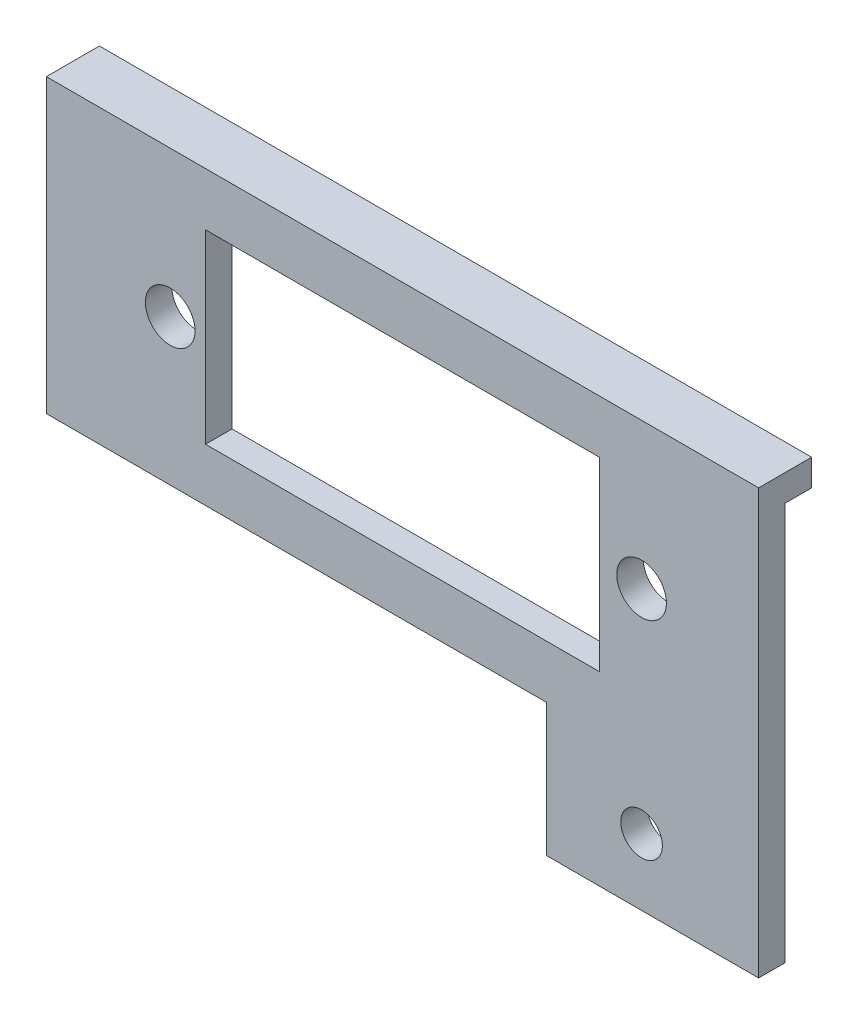
from build123d import *

# Parameters (mm, degrees)
SKETCH1_R           = 2.9718
SKETCH1_W           = 47.1424
SKETCH1_H           = 22.225
SKETCH1_R_2         = 2.4892
BOSS_EXTRUDE1_DEPTH = 3.175
SKETCH2_W           = 85.2424
SKETCH2_H           = 3.175
BOSS_EXTRUDE2_DEPTH = 3.175


with BuildPart() as part:
    # Sketch1 → Boss-Extrude1 (new body)
    with BuildSketch(Plane.XY):
        Polygon((37.4777, 9.5377), (24.7777, 9.5377), (-35.0647, 9.5377), (-47.7647, 9.5377), (-47.7647, -25.3873), (-35.0647, -25.3873), (12.0777, -25.3873), (24.7777, -25.3873), (37.4777, -25.3873), align=None)
        with Locations((-32.941818083, -7.9248)):
            Circle(SKETCH1_R, mode=Mode.SUBTRACT)
        with Locations((-5.1435, -7.9248)):
            Rectangle(SKETCH1_W, SKETCH1_H, mode=Mode.SUBTRACT)
        with Locations((23.471581917, -7.9248)):
            Circle(SKETCH1_R, mode=Mode.SUBTRACT)
        Polygon((37.4777, -41.2623), (37.4777, -25.3873), (24.7777, -25.3873), (12.0777, -25.3873), (12.0777, -41.2623), align=None)
        with Locations((23.471581917, -33.3248)):
            Circle(SKETCH1_R_2, mode=Mode.SUBTRACT)
    extrude(amount=BOSS_EXTRUDE1_DEPTH)

    # Sketch2 → Boss-Extrude2 (add)
    with BuildSketch(Plane(origin=(0, 0, 0), x_dir=(-1, 0, 0), z_dir=(0, 0, -1))):
        with Locations((5.1435, 7.9502)):
            Rectangle(SKETCH2_W, SKETCH2_H)
    extrude(amount=BOSS_EXTRUDE2_DEPTH)


solid = part.part
